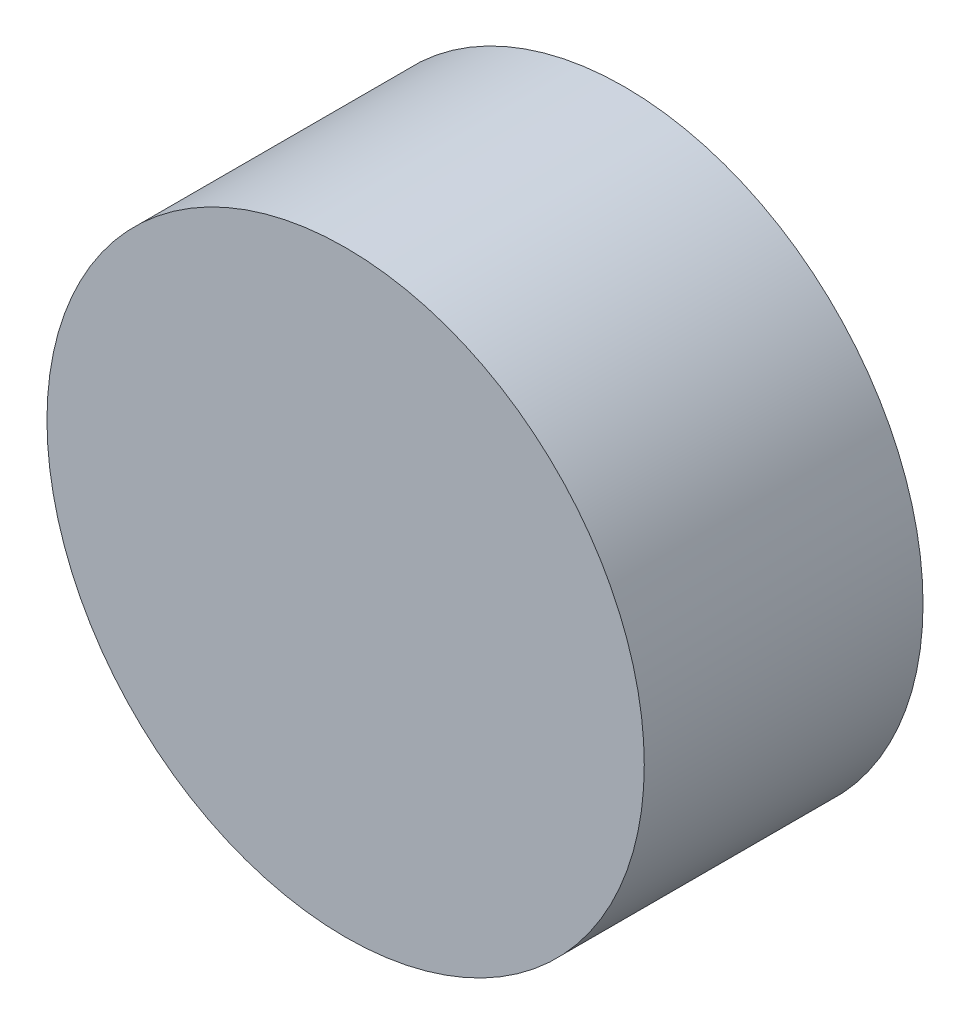
from build123d import *

# Parameters (mm, degrees)
SKETCH1_R           = 9.525
BOSS_EXTRUDE1_DEPTH = 8.89


with BuildPart() as part:
    # Sketch1 → Boss-Extrude1 (new body)
    with BuildSketch(Plane.XY):
        Circle(SKETCH1_R)
    extrude(amount=BOSS_EXTRUDE1_DEPTH)


solid = part.part
